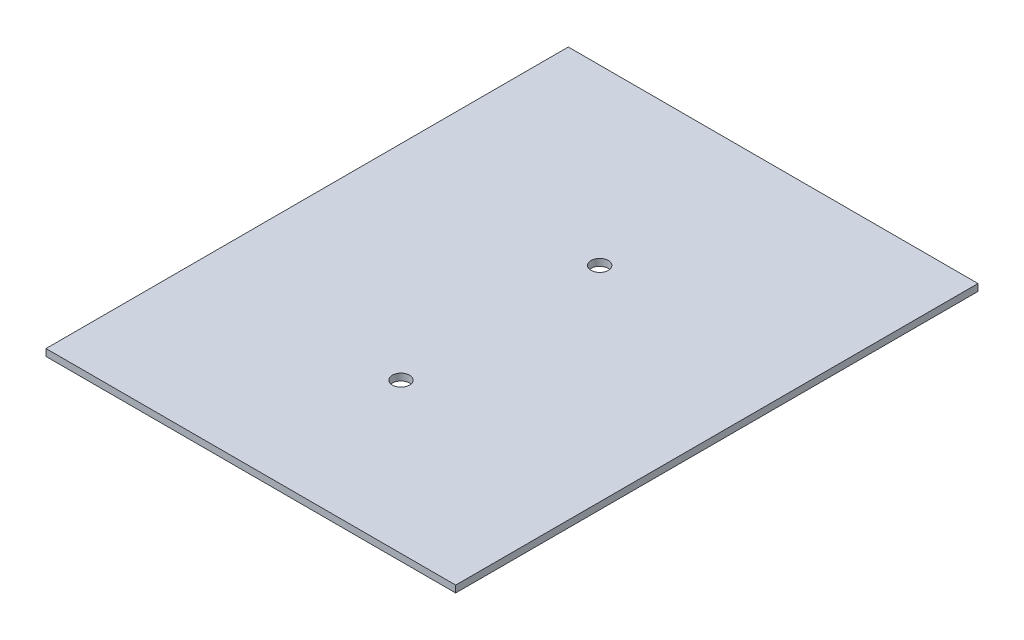
from build123d import *

# Parameters (mm, degrees)
SKETCH1_W           = 238.097201903
SKETCH1_H           = 303.557386745
SKETCH1_R           = 5
BOSS_EXTRUDE1_DEPTH = 4


with BuildPart() as part:
    # Sketch1 → Boss-Extrude1 (new body)
    with BuildSketch(Plane(origin=(0, 0, 0), x_dir=(1, 0, 0), z_dir=(0, 1, 0))):
        with Locations((83.287897072, -6.210168708)):
            Rectangle(SKETCH1_W, SKETCH1_H)
        with Locations(Location((83.287897072, 44.735608732, 0), (0, 0, 270))):  # turned: the seam where the file's is
            Circle(SKETCH1_R, mode=Mode.SUBTRACT)
        with Locations(Location((83.287897072, -70.734445106, 0), (0, 0, 270))):  # turned: the seam where the file's is
            Circle(SKETCH1_R, mode=Mode.SUBTRACT)
    extrude(amount=BOSS_EXTRUDE1_DEPTH)


solid = part.part
